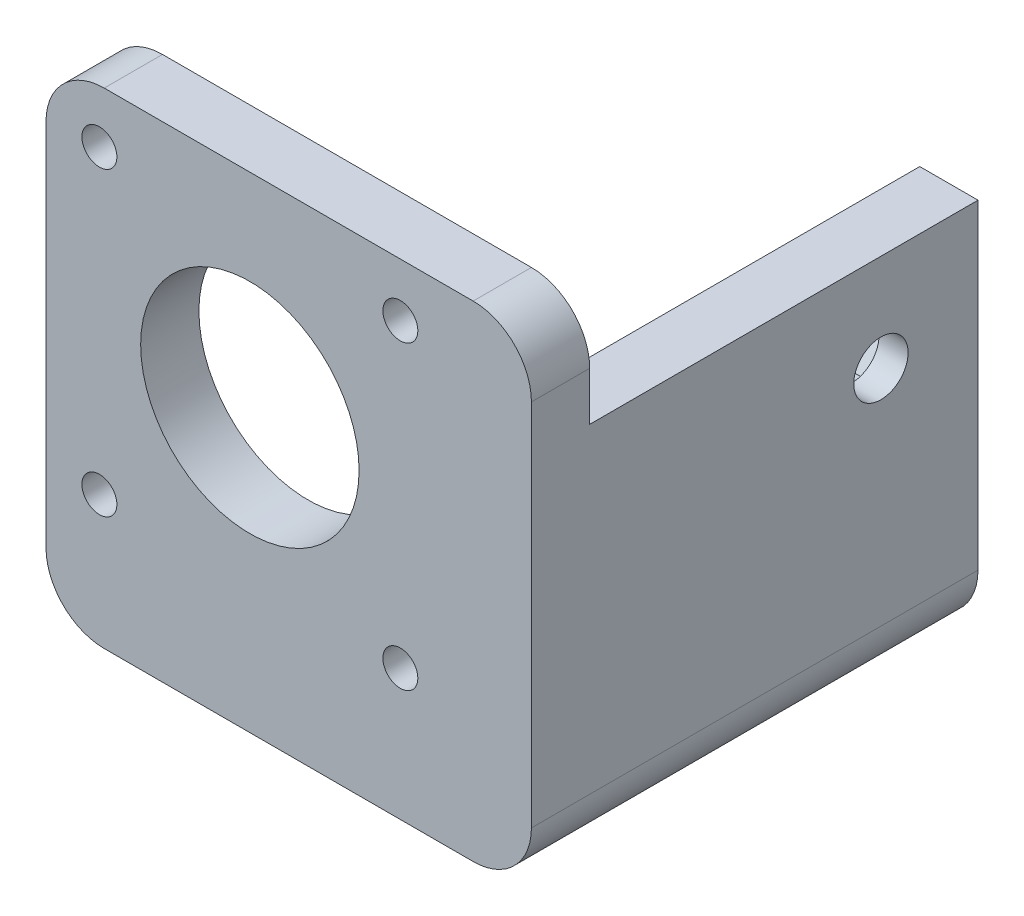
from build123d import *

# Parameters (mm, degrees)
SKETCH1_W              = 50
SKETCH1_H              = 50
BOSS_EXTRUDE1_DEPTH    = 6
BOSS_EXTRUDE2_DEPTH    = 40
F_3_6MM_DOWEL_HOLE1_D  = 3.6
F_22_5MM_DOWEL_HOLE1_D = 22.5
F_5_6MM_DOWEL_HOLE1_D  = 5.6
F_5_6MM_DOWEL_HOLE2_D  = 5.6
CUT_EXTRUDE1_DEPTH     = 3
CUT_EXTRUDE2_DEPTH     = 3
FILLET1_R              = 6


with BuildPart() as part:
    # Sketch1 → Boss-Extrude1 (new body)
    with BuildSketch(Plane.XY):
        with Locations((-25, 25)):
            Rectangle(SKETCH1_W, SKETCH1_H)
    extrude(amount=-BOSS_EXTRUDE1_DEPTH)

    # Sketch2 → Boss-Extrude2 (add)
    with BuildSketch(Plane(origin=(0, 0, -6), x_dir=(-1, 0, 0), z_dir=(0, 0, -1))):
        Polygon((0, 39), (6, 39), (6, 6), (34, 6), (34, 0), (6, 0), (0, 0), align=None)
    extrude(amount=BOSS_EXTRUDE2_DEPTH)

    # Ø3.6mm Dowel Hole1 (through all)
    with Locations(Plane.XY):
        with Locations((-44.5, 44.5), (-13.5, 44.5), (-13.5, 13.5), (-44.5, 13.5)):
            Hole(F_3_6MM_DOWEL_HOLE1_D / 2)

    # Ø22.5mm Dowel Hole1 (through all)
    with Locations(Plane.XY):
        with Locations((-29, 29)):
            Hole(F_22_5MM_DOWEL_HOLE1_D / 2)

    # Ø5.6mm Dowel Hole1 (through all)
    with Locations(Plane(origin=(0, 29, -36), x_dir=(0, 0, 1), z_dir=(1, 0, 0))):
        with Locations((0, 0)):
            Hole(F_5_6MM_DOWEL_HOLE1_D / 2)

    # Ø5.6mm Dowel Hole2 (through all)
    with Locations(Plane(origin=(0, 0, 0), x_dir=(-1, 0, 0), z_dir=(0, -1, 0))):
        with Locations((24, 15)):
            Hole(F_5_6MM_DOWEL_HOLE2_D / 2)

    # Sketch12 → Cut-Extrude1 (cut)
    with BuildSketch(Plane(origin=(0, 6, 0), x_dir=(1, 0, 0), z_dir=(0, 1, 0))):
        Polygon((-28.2, 12.575128869), (-24, 10.150257739), (-19.8, 12.575128869), (-19.8, 17.424871131), (-24, 19.849742261), (-28.2, 17.424871131), align=None)
    extrude(amount=-CUT_EXTRUDE1_DEPTH, mode=Mode.SUBTRACT)

    # Sketch13 → Cut-Extrude2 (cut)
    with BuildSketch(Plane.ZY.offset(6)):
        Polygon((-40.849742261, 29), (-38.424871131, 24.8), (-33.575128869, 24.8), (-31.150257739, 29), (-33.575128869, 33.2), (-38.424871131, 33.2), align=None)
    extrude(amount=-CUT_EXTRUDE2_DEPTH, mode=Mode.SUBTRACT)

    # Fillet1
    fillet1_edges = [part.edges().sort_by_distance(p)[0] for p in [
        (-50, 50, -3),
        (0, 50, -3),
        (0, 0, -23),
        (-50, 0, -3),
    ]]
    fillet(fillet1_edges, radius=FILLET1_R)


solid = part.part
